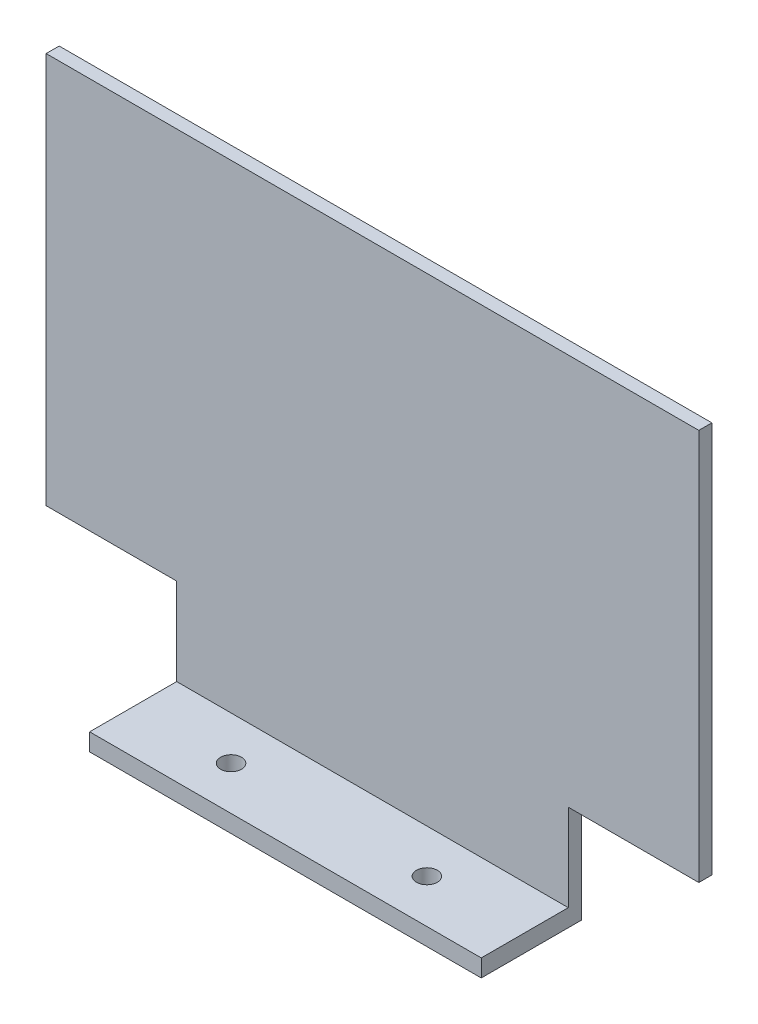
from build123d import *

# Parameters (mm, degrees)
SKETCH_1_W          = 150
SKETCH_1_H          = 90
EXTRUDE_1_DEPTH     = 3
SKETCH_2_W          = 90
SKETCH_2_H          = 20
EXTRUDE_2_DEPTH     = 3
SKETCH_3_W          = 90
SKETCH_3_H          = 4
EXTRUDE_3_DEPTH     = 23
CUT_EXTRUDE_1_REACH = 116
SKETCH_4_R          = 2.4


with BuildPart() as part:
    # 스케치1 → 보스-돌출1 (new body)
    with BuildSketch(Plane.XY):
        Rectangle(SKETCH_1_W, SKETCH_1_H)
    extrude(amount=EXTRUDE_1_DEPTH)

    # 스케치2 → 보스-돌출2 (add)
    with BuildSketch(Plane.XY):
        with Locations((0, -55)):
            Rectangle(SKETCH_2_W, SKETCH_2_H)
    extrude(amount=EXTRUDE_2_DEPTH)

    # 스케치3 → 보스-돌출3 (add)
    with BuildSketch(Plane.XY):
        with Locations((0, -67)):
            Rectangle(SKETCH_3_W, SKETCH_3_H)
    extrude(amount=EXTRUDE_3_DEPTH)

    # 스케치4 → 컷-돌출1 (cut, up to next)
    with BuildSketch(Plane.XZ.offset(69), mode=Mode.PRIVATE) as cut_extrude_1_sk1:
        with Locations((-22.5, 13)):
            Circle(SKETCH_4_R)
    cut_extrude_1_tool1 = extrude(cut_extrude_1_sk1.sketch, amount=-CUT_EXTRUDE_1_REACH, mode=Mode.PRIVATE) & part.part
    add(cut_extrude_1_tool1.solids().sort_by_distance((-22.5, -69, 13))[0], mode=Mode.SUBTRACT)
    # 스케치4 → 컷-돌출1 (cut, up to next)
    with BuildSketch(Plane.XZ.offset(69), mode=Mode.PRIVATE) as cut_extrude_1_sk2:
        with Locations((22.5, 13)):
            Circle(SKETCH_4_R)
    cut_extrude_1_tool2 = extrude(cut_extrude_1_sk2.sketch, amount=-CUT_EXTRUDE_1_REACH, mode=Mode.PRIVATE) & part.part
    add(cut_extrude_1_tool2.solids().sort_by_distance((22.5, -69, 13))[0], mode=Mode.SUBTRACT)


solid = part.part
